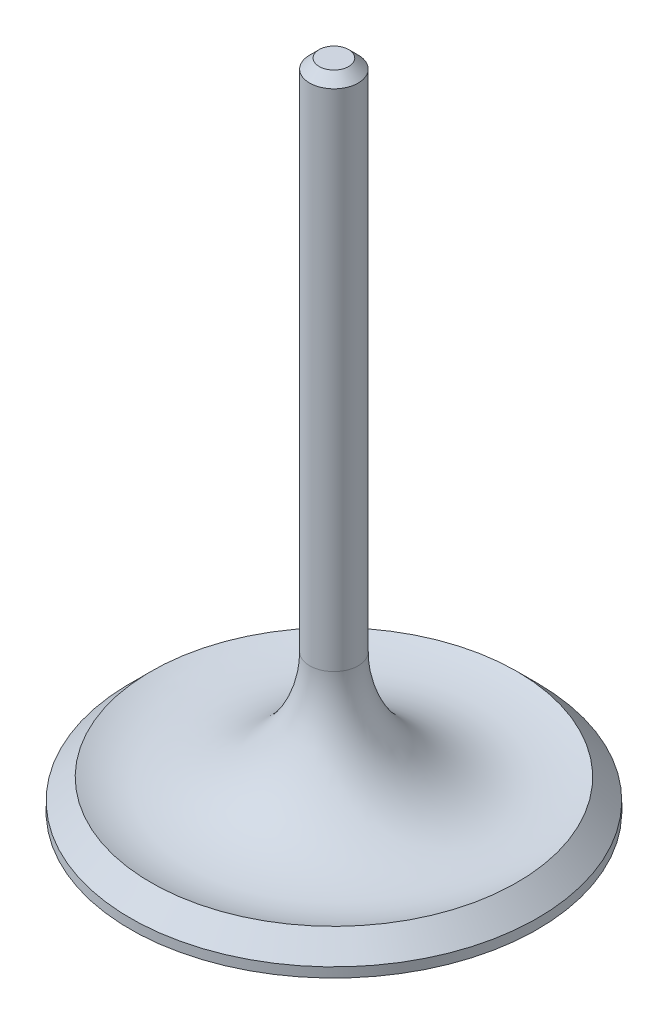
from build123d import *

# Parameters (mm, degrees)
CHANFREIN1_SIZE = 1.25


with BuildPart() as part:
    # Esquisse1 → Révolution1 (revolve)
    with BuildSketch(Plane(origin=(0, 0, 0), x_dir=(0, 0, -1), z_dir=(1, 0, 0))):
        with BuildLine():
            Line((0, 0), (0, 85.55))
            Line((0, 85.55), (3.18, 85.55))
            Line((3.18, 85.55), (3.18, 18.169893823))
            ThreePointArc((3.18, 18.169893823), (9.828047554, 5.577478879), (23.975923164, 3.964076836))
            Line((23.975923164, 3.964076836), (26.67, 1.27))
            Line((26.67, 1.27), (26.67, 0))
            Line((26.67, 0), (0, 0))
        make_face()
    revolve(axis=Axis((0, 0, 0), (0, 1, 0)))

    # Chanfrein1
    chanfrein1_edges = [part.edges().sort_by_distance(p)[0] for p in [
        (0, 85.55, 3.18),
    ]]
    chamfer(chanfrein1_edges, length=CHANFREIN1_SIZE)


solid = part.part
